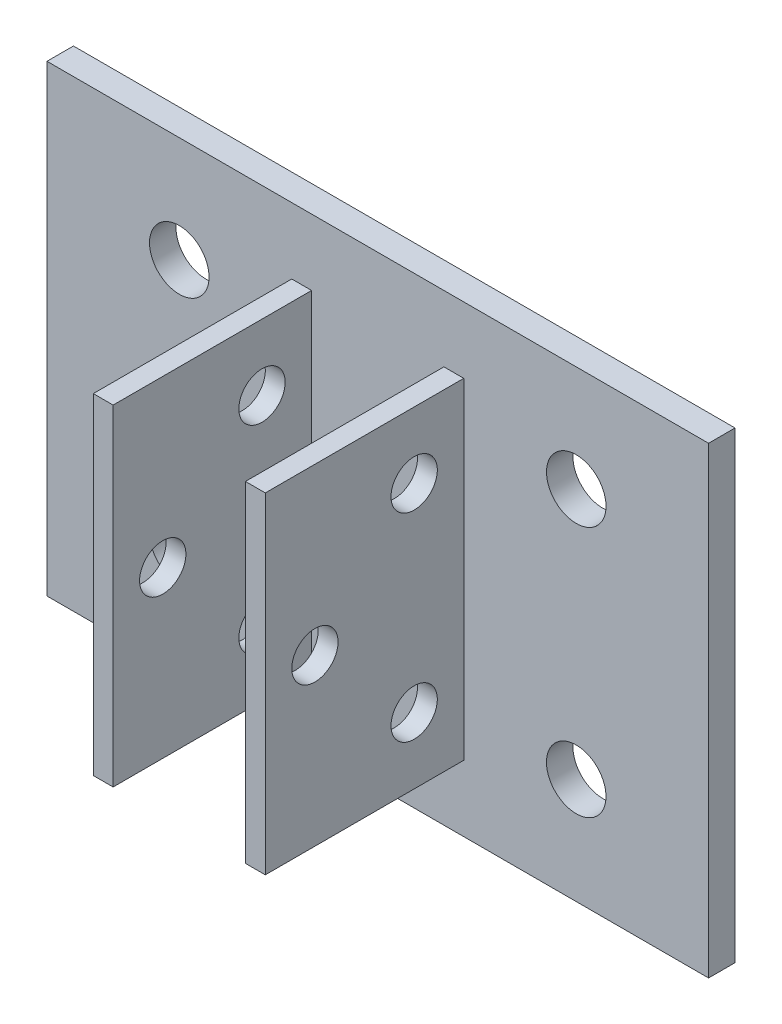
from build123d import *

# Parameters (mm, degrees)
SKETCH2_W           = 50
SKETCH2_H           = 35
SKETCH2_R           = 2.25
BOSS_EXTRUDE1_DEPTH = 2
SKETCH3_W           = 1.5
SKETCH3_H           = 25
BOSS_EXTRUDE2_DEPTH = 15
SKETCH4_R           = 1.75
CUT_EXTRUDE1_DEPTH  = 32.5


with BuildPart() as part:
    # Sketch2 → Boss-Extrude1 (new body)
    with BuildSketch(Plane.XY):
        Rectangle(SKETCH2_W, SKETCH2_H)
        with Locations((15, 9.5)):
            Circle(SKETCH2_R, mode=Mode.SUBTRACT)
        with Locations((-15, 9.5)):
            Circle(SKETCH2_R, mode=Mode.SUBTRACT)
        with Locations((-15, -9.5)):
            Circle(SKETCH2_R, mode=Mode.SUBTRACT)
        with Locations((15, -9.5)):
            Circle(SKETCH2_R, mode=Mode.SUBTRACT)
    extrude(amount=BOSS_EXTRUDE1_DEPTH)

    # Sketch3 → Boss-Extrude2 (add)
    with BuildSketch(Plane.XY.offset(2)):
        with Locations((-5.75, 0)):
            Rectangle(SKETCH3_W, SKETCH3_H)
        with Locations((5.75, 0)):
            Rectangle(SKETCH3_W, SKETCH3_H)
    extrude(amount=BOSS_EXTRUDE2_DEPTH)

    # Sketch4 → Cut-Extrude1 (cut, through all)
    with BuildSketch(Plane.ZY.offset(6.5)):
        with Locations((5.75, -7.5)):
            Circle(SKETCH4_R)
        with Locations((5.75, 7.5)):
            Circle(SKETCH4_R)
        with Locations((13.25, 0)):
            Circle(SKETCH4_R)
    extrude(amount=-CUT_EXTRUDE1_DEPTH, mode=Mode.SUBTRACT)


solid = part.part
